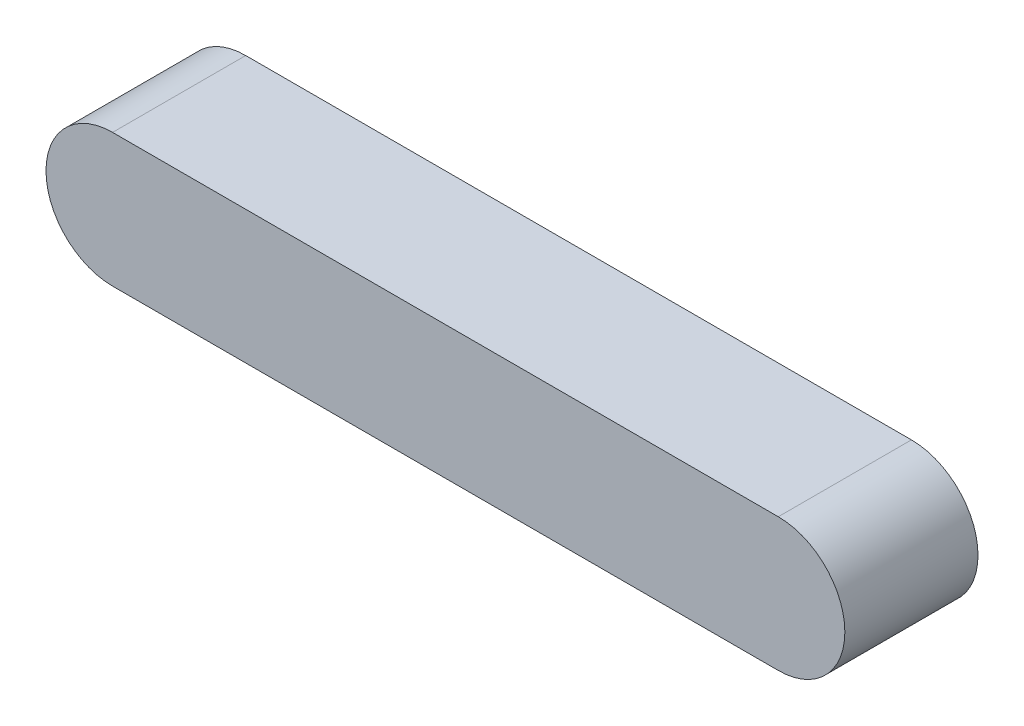
from build123d import *

# Parameters (mm, degrees)
BOSS_EXTRUDE1_DEPTH = 50.8


with BuildPart() as part:
    # Sketch1 → Boss-Extrude1 (new body)
    with BuildSketch(Plane.XY):
        with BuildLine():
            Line((-127, 25.4), (127, 25.4))
            ThreePointArc((127, 25.4), (152.4, 0), (127, -25.4))
            Line((127, -25.4), (-127, -25.4))
            ThreePointArc((-127, -25.4), (-152.4, 0), (-127, 25.4))
        make_face()
    extrude(amount=BOSS_EXTRUDE1_DEPTH)


solid = part.part
